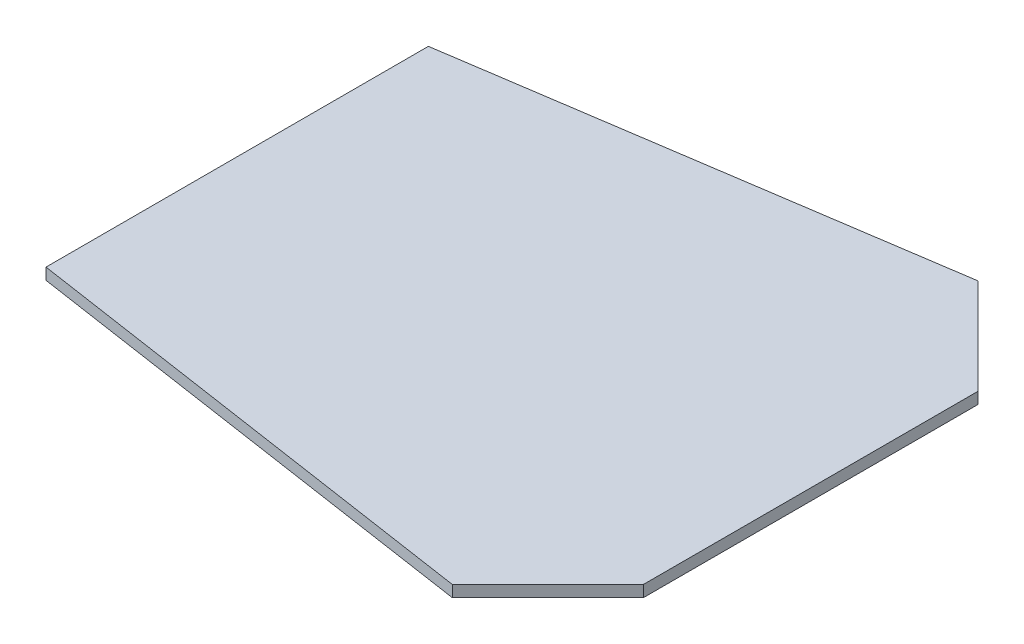
from build123d import *

# Parameters (mm, degrees)
BOSS_EXTRUDE1_DEPTH = 12


with BuildPart() as part:
    # Sketch1 → Boss-Extrude1 (new body)
    with BuildSketch(Plane(origin=(0, 0, 0), x_dir=(1, 0, 0), z_dir=(0, 1, 0))):
        Polygon((0, 0), (0, 400), (500, 475), (600, 375), (600, 25), (500, -75), align=None)
    extrude(amount=BOSS_EXTRUDE1_DEPTH)


solid = part.part
